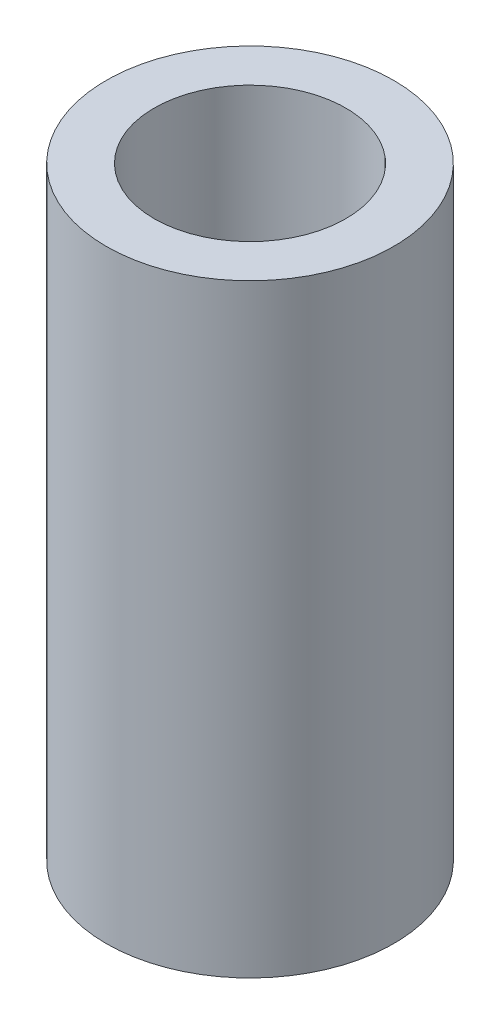
from build123d import *

# Parameters (mm, degrees)
SKETCH2_R   = 4.7625
SKETCH2_R_2 = 3.175


with BuildPart() as part:
    # Sweep2: sweep along a path in Sketch4
    with BuildLine(Plane(origin=(0, 0, 0), x_dir=(0, 0, -1), z_dir=(1, 0, 0))) as sweep2_path:
        Line((8, 0), (8, 20))
    # Sketch2 → Sweep2 (sweep)
    with BuildSketch(Plane(origin=(0, 0, 0), x_dir=(1, 0, 0), z_dir=(0, 1, 0))):
        with Locations((0, 8)):
            Circle(SKETCH2_R)
        with Locations((0, 8)):
            Circle(SKETCH2_R_2, mode=Mode.SUBTRACT)
    sweep(path=sweep2_path.line)


solid = part.part
